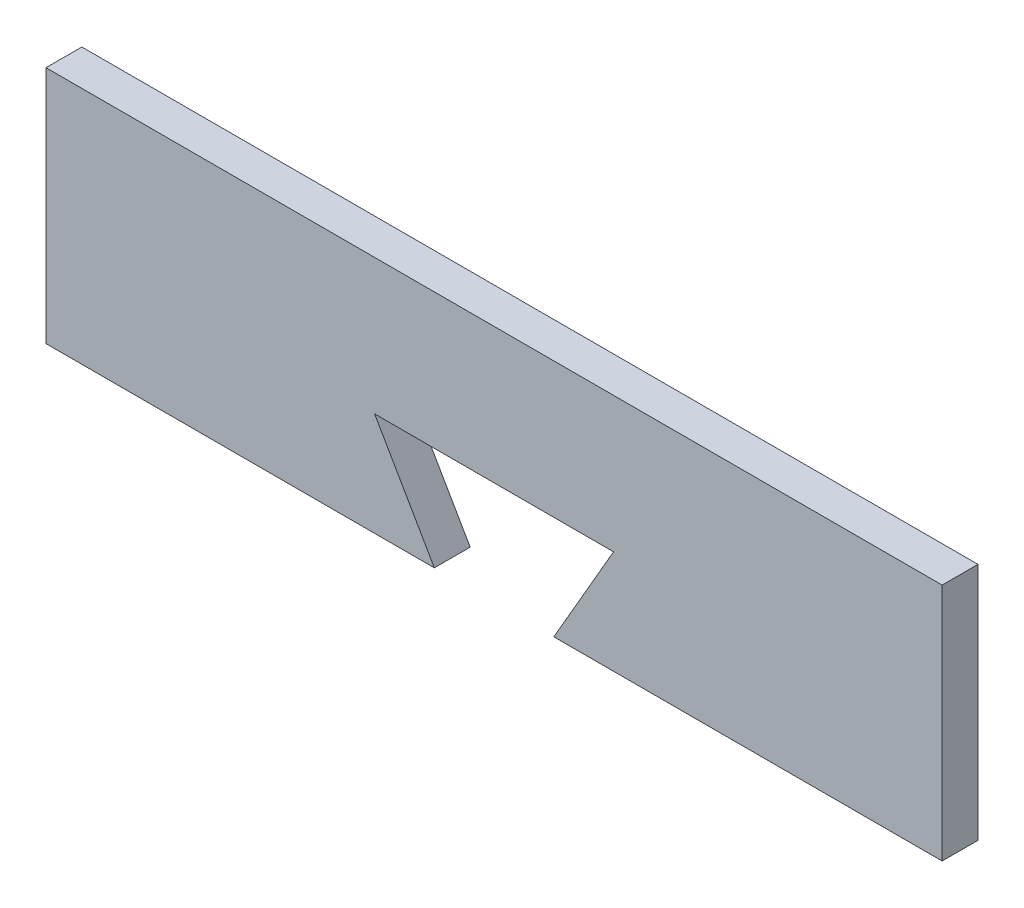
from build123d import *

# Parameters (mm, degrees)
BOSS_EXTRU_1_DEPTH = 6


with BuildPart() as part:
    # Esquisse1 → Boss.-Extru.1 (new body)
    with BuildSketch(Plane.XY):
        Polygon((-84.834932582, 29.122137405), (65.165067418, 29.122137405), (65.165067418, -10.877862595), (0.165067418, -10.877862595), (10.165067418, 6.44264548), (-29.834932582, 6.44264548), (-19.834932582, -10.877862595), (-84.834932582, -10.877862595), align=None)
    extrude(amount=BOSS_EXTRU_1_DEPTH)


solid = part.part
